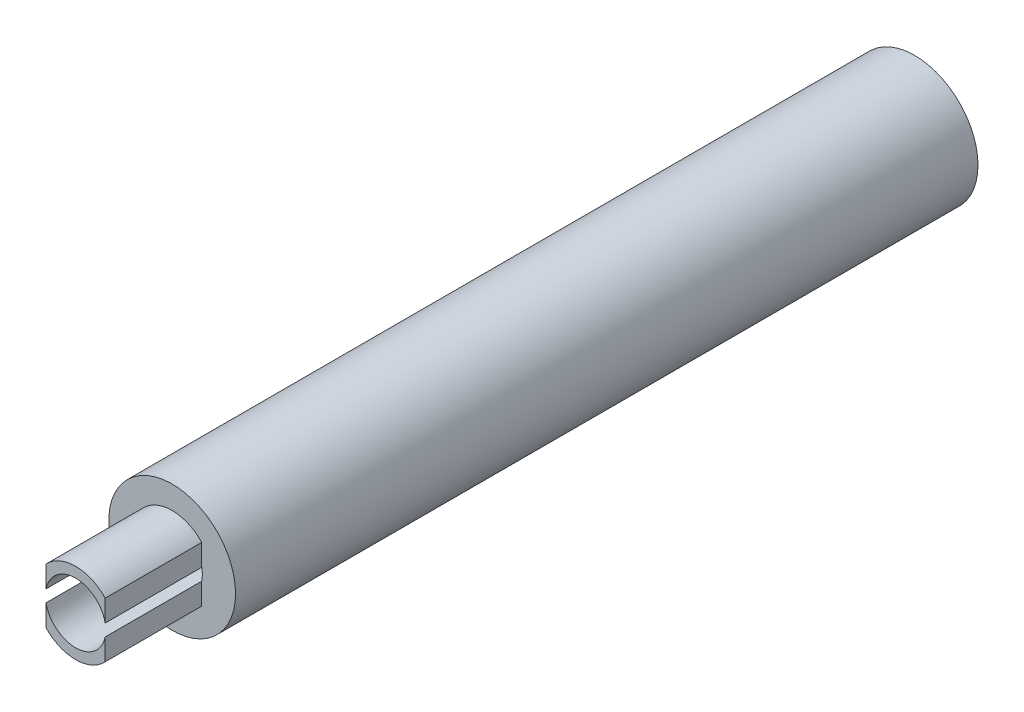
from build123d import *

# Parameters (mm, degrees)
SZKIC1_R                    = 5.25
DODANIE_WYCI_GNI_CIE1_DEPTH = 61.5
SZKIC3_R                    = 3.35
DODANIE_WYCI_GNI_CIE2_DEPTH = 8
SZKIC4_R                    = 2.5
WYTNIJ_WYCI_GNI_CIE2_DEPTH  = 70.5
SZKIC7_R                    = 3.05
WYTNIJ_WYCI_GNI_CIE4_DEPTH  = 18
WYTNIJ_WYCI_GNI_CIE8_DEPTH  = 8


with BuildPart() as part:
    # Szkic1 → Dodanie-wyciągnięcie1 (new body)
    with BuildSketch(Plane.XY):
        Circle(SZKIC1_R)
    extrude(amount=DODANIE_WYCI_GNI_CIE1_DEPTH)

    # Szkic3 → Dodanie-wyciągnięcie2 (add)
    with BuildSketch(Plane.XY.offset(61.5)):
        Circle(SZKIC3_R)
    extrude(amount=DODANIE_WYCI_GNI_CIE2_DEPTH)

    # Szkic4 → Wytnij-wyciągnięcie2 (cut, through all)
    with BuildSketch(Plane.XY.offset(69.5)):
        Circle(SZKIC4_R)
    extrude(amount=-WYTNIJ_WYCI_GNI_CIE2_DEPTH, mode=Mode.SUBTRACT)

    # Szkic7 → Wytnij-wyciągnięcie4 (cut)
    with BuildSketch(Plane(origin=(0, 0, 0), x_dir=(-1, 0, 0), z_dir=(0, 0, -1))):
        Circle(SZKIC7_R)
    extrude(amount=-WYTNIJ_WYCI_GNI_CIE4_DEPTH, mode=Mode.SUBTRACT)

    # Szkic10 → Wytnij-wyciągnięcie8 (cut)
    with BuildSketch(Plane.XY.offset(69.5)):
        Polygon((-2.5, 4.616546328), (-2.45, 4.616546328), (-2.45, -4.155907231), (-2.5, -4.155907231), (-5.821141217, -4.155907231), (-5.821141217, 4.616546328), align=None)
        Polygon((2.5, 4.616546328), (2.45, 4.616546328), (2.45, -4.055418973), (2.5, -4.055418973), (5.892918543, -4.155907231), (5.892918543, 4.616546328), align=None)
    extrude(amount=-WYTNIJ_WYCI_GNI_CIE8_DEPTH, mode=Mode.SUBTRACT)


solid = part.part
